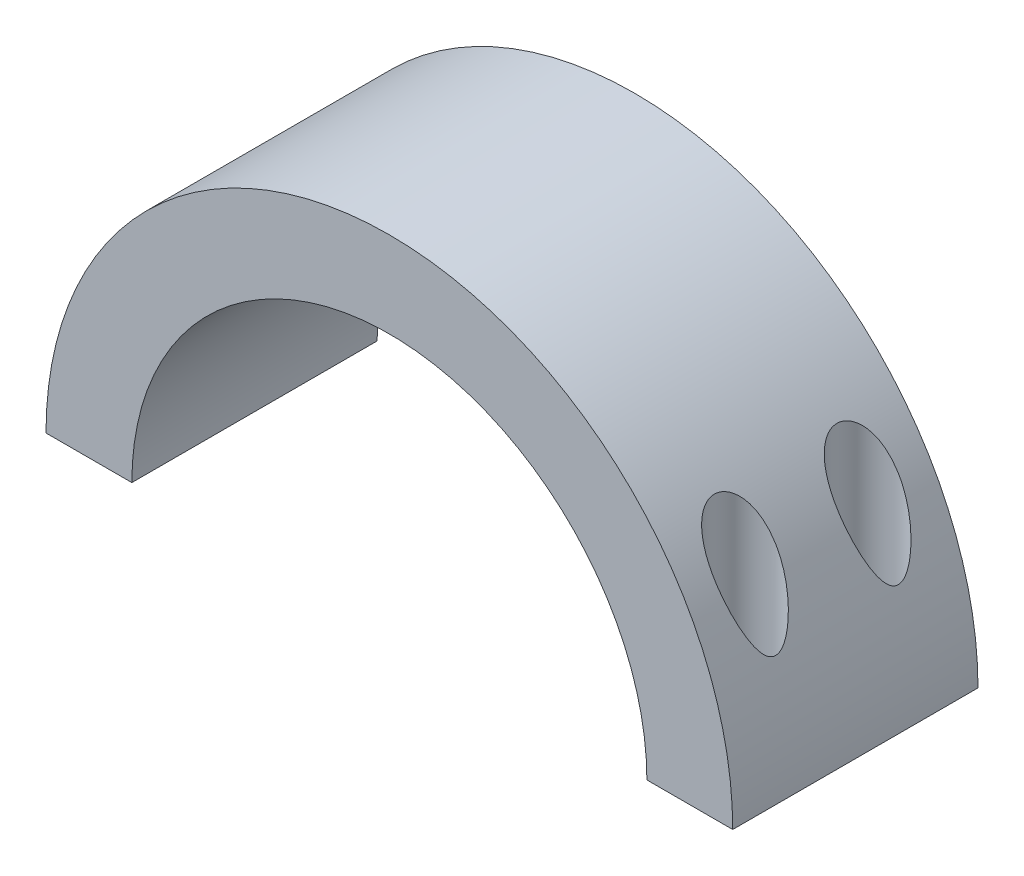
from build123d import *

# Parameters (mm, degrees)
EXTRUDE_1_DEPTH     = 20
SKETCH_2_R          = 1.5
CUT_EXTRUDE_1_DEPTH = 20
SKETCH_3_R          = 2.5
CUT_EXTRUDE_2_DEPTH = 20


with BuildPart() as part:
    # 草图1 → 凸台-拉伸1 (new body)
    with BuildSketch(Plane.XY):
        with BuildLine():
            Line((-28, 0), (-21, 0))
            ThreePointArc((-21, 0), (0, 21), (21, 0))
            Line((21, 0), (28, 0))
            ThreePointArc((28, 0), (0, 28), (-28, 0))
        make_face()
    extrude(amount=EXTRUDE_1_DEPTH)

    # 草图2 → 切除-拉伸1 (cut)
    with BuildSketch(Plane.XZ):
        with Locations((-24, 5)):
            Circle(SKETCH_2_R)
        with Locations((-24, 15)):
            Circle(SKETCH_2_R)
    cut_extrude_1 = extrude(amount=-CUT_EXTRUDE_1_DEPTH, mode=Mode.SUBTRACT)

    # 镜向1: 切除-拉伸1 across plane
    add(cut_extrude_1.mirror(Plane(origin=(0, 0, 0), x_dir=(0, 0, 1), z_dir=(1, 0, 0))), mode=Mode.SUBTRACT)

    # 草图3 → 切除-拉伸2 (cut)
    with BuildSketch(Plane(origin=(0, 5, 0), x_dir=(-1, 0, 0), z_dir=(0, -1, 0))):
        with Locations((24, -5)):
            Circle(SKETCH_3_R)
        with Locations((24, -15)):
            Circle(SKETCH_3_R)
    cut_extrude_2 = extrude(amount=-CUT_EXTRUDE_2_DEPTH, mode=Mode.SUBTRACT)

    # 镜向2: 切除-拉伸2 across plane
    add(cut_extrude_2.mirror(Plane(origin=(0, 0, 0), x_dir=(0, 0, 1), z_dir=(1, 0, 0))), mode=Mode.SUBTRACT)


solid = part.part
